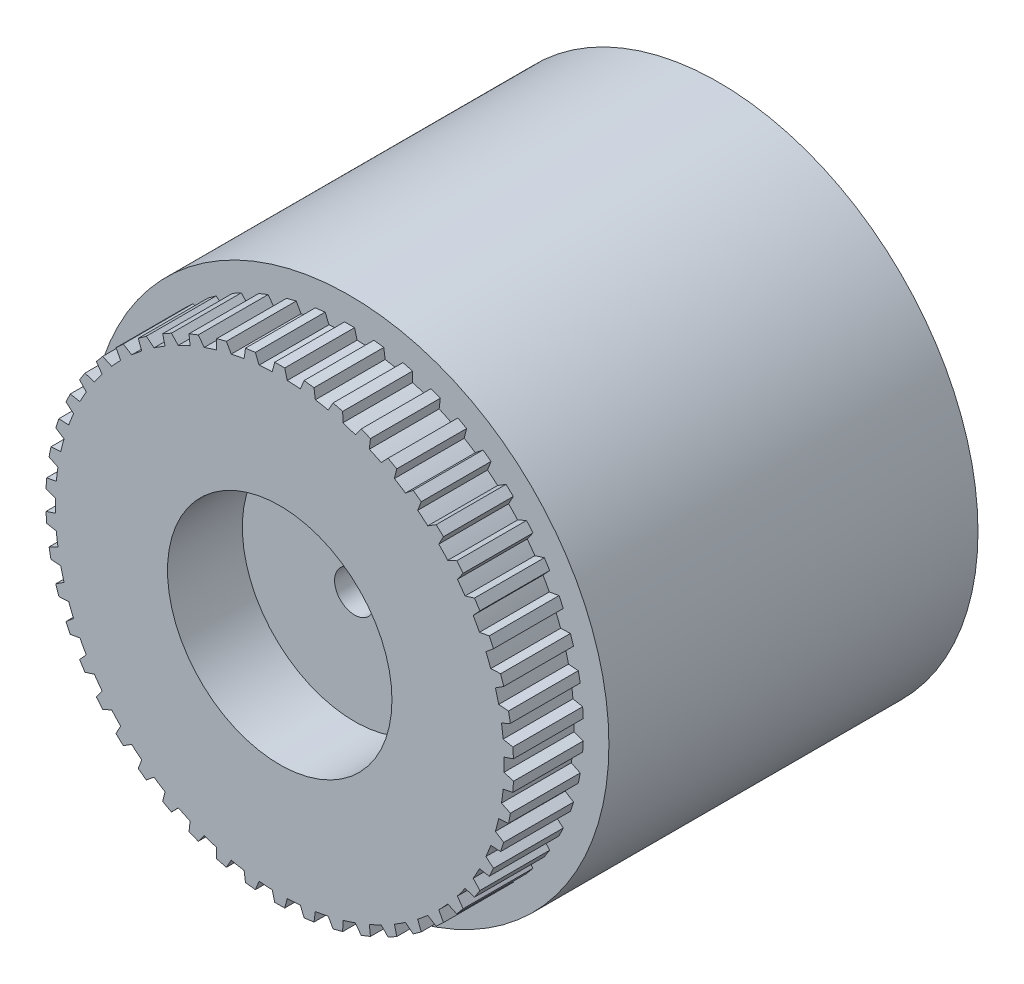
from build123d import *

# Parameters (mm, degrees)
SKETCH1_R           = 26
BOSS_EXTRUDE1_DEPTH = 37
SKETCH2_R           = 22.5
BOSS_EXTRUDE2_DEPTH = 7
BOSS_EXTRUDE3_DEPTH = 7
CIRPATTERN1_COUNT   = 50
SKETCH4_R           = 6.75
CUT_EXTRUDE1_DEPTH  = 5.5
SKETCH5_R           = 2
CUT_EXTRUDE2_DEPTH  = 39.5
SKETCH6_R           = 11.25
CUT_EXTRUDE3_DEPTH  = 7.5


with BuildPart() as part:
    # Sketch1 → Boss-Extrude1 (new body)
    with BuildSketch(Plane.XY):
        Circle(SKETCH1_R)
    extrude(amount=BOSS_EXTRUDE1_DEPTH)

    # Sketch2 → Boss-Extrude2 (add)
    with BuildSketch(Plane.XY.offset(37)):
        Circle(SKETCH2_R)
    extrude(amount=BOSS_EXTRUDE2_DEPTH)

    # Sketch3 → Boss-Extrude3 (add)
    with BuildSketch(Plane.XY.offset(44)):
        Polygon((0, 23.445373418), (-0.5, 23.445373418), (-1.79775122, 18.602099929), (1.79775122, 18.602099929), (0.5, 23.445373418), align=None)
    boss_extrude3 = extrude(amount=-BOSS_EXTRUDE3_DEPTH)

    # CirPattern1: Boss-Extrude3 ×50 about axis
    cirpattern1_axis = Axis((0, 0, 0), (0, 0, 1))
    for i in range(1, CIRPATTERN1_COUNT):
        add(boss_extrude3.rotate(cirpattern1_axis, i * 360 / CIRPATTERN1_COUNT))

    # Sketch4 → Cut-Extrude1 (cut)
    with BuildSketch(Plane(origin=(0, 0, 0), x_dir=(-1, 0, 0), z_dir=(0, 0, -1))):
        Circle(SKETCH4_R)
    extrude(amount=-CUT_EXTRUDE1_DEPTH, mode=Mode.SUBTRACT)

    # Sketch5 → Cut-Extrude2 (cut, through all)
    with BuildSketch(Plane(origin=(0, 0, 5.5), x_dir=(-1, 0, 0), z_dir=(0, 0, -1))):
        Circle(SKETCH5_R)
    extrude(amount=-CUT_EXTRUDE2_DEPTH, mode=Mode.SUBTRACT)

    # Sketch6 → Cut-Extrude3 (cut)
    with BuildSketch(Plane.XY.offset(44)):
        Circle(SKETCH6_R)
    extrude(amount=-CUT_EXTRUDE3_DEPTH, mode=Mode.SUBTRACT)


solid = part.part
